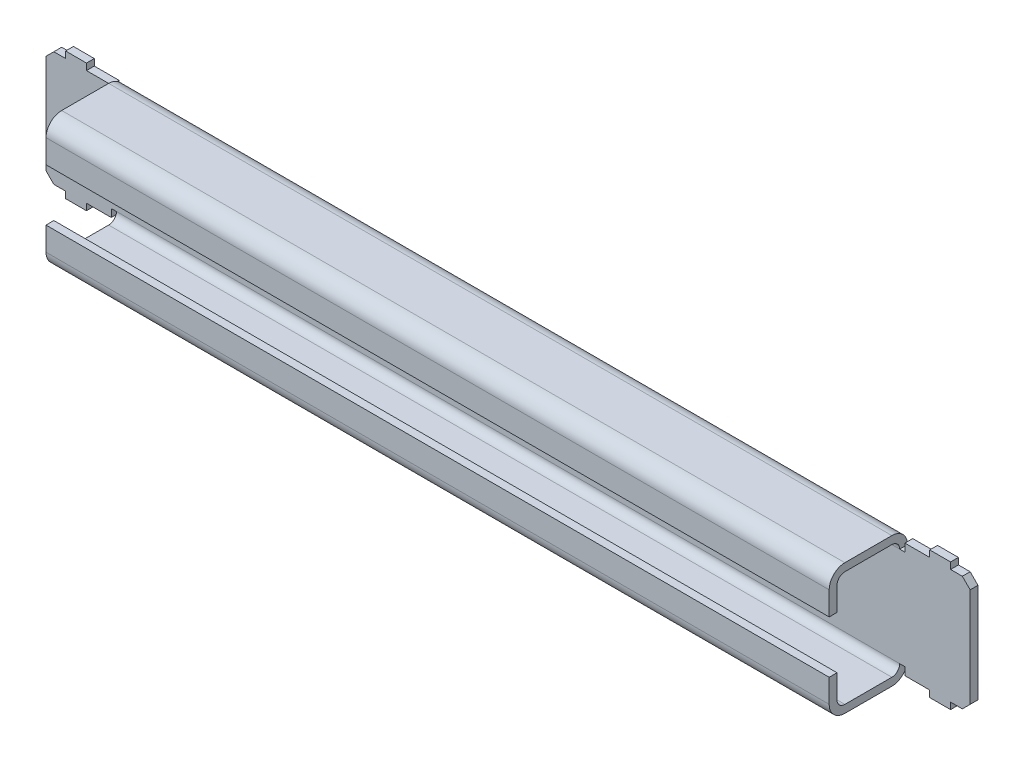
from build123d import *

# Parameters (mm, degrees)
BOSS_EXTRUDE1_DEPTH = 150
FILLET1_R           = 6
FILLET2_R           = 3
BOSS_EXTRUDE2_DEPTH = 3


with BuildPart() as part:
    # Sketch2 → Boss-Extrude1 (new body, symmetric)
    with BuildSketch(Plane(origin=(0, 0, 0), x_dir=(0, 0, -1), z_dir=(1, 0, 0))):
        Polygon((0, 0), (30, 0), (30, 50), (0, 50), (0, 35), (3, 35), (3, 47), (27, 47), (27, 3), (3, 3), (3, 15), (0, 15), align=None)
    extrude(amount=BOSS_EXTRUDE1_DEPTH, both=True)

    # Fillet1
    fillet1_edges = [part.edges().sort_by_distance(p)[0] for p in [
        (0, 50, 0),
        (0, 50, -30),
        (0, 0, -30),
        (0, 0, 0),
    ]]
    fillet(fillet1_edges, radius=FILLET1_R)

    # Fillet2
    fillet2_edges = [part.edges().sort_by_distance(p)[0] for p in [
        (0, 3, -3),
        (0, 3, -27),
        (0, 47, -27),
        (0, 47, -3),
    ]]
    fillet(fillet2_edges, radius=FILLET2_R)

    # Sketch3 → Boss-Extrude2 (add)
    with BuildSketch(Plane.XY.offset(-27)):
        Polygon((-150, 44), (-152, 44), (-152, 47), (-161.5, 47), (-161.5, 49.5), (-169.5, 49.5), (-169.5, 47), (-174, 47), (-177, 44), (-177, 6), (-174, 3), (-169.5, 3), (-169.5, 0.5), (-161.5, 0.5), (-161.5, 3), (-152, 3), (-152, 6), (-150, 6), align=None)
        Polygon((174, 3), (177, 6), (177, 44), (174, 47), (169.5, 47), (169.5, 49.5), (161.5, 49.5), (161.5, 47), (152, 47), (152, 44), (150, 44), (150, 6), (152, 6), (152, 3), (161.5, 3), (161.5, 0.5), (169.5, 0.5), (169.5, 3), align=None)
    extrude(amount=-BOSS_EXTRUDE2_DEPTH)


solid = part.part
